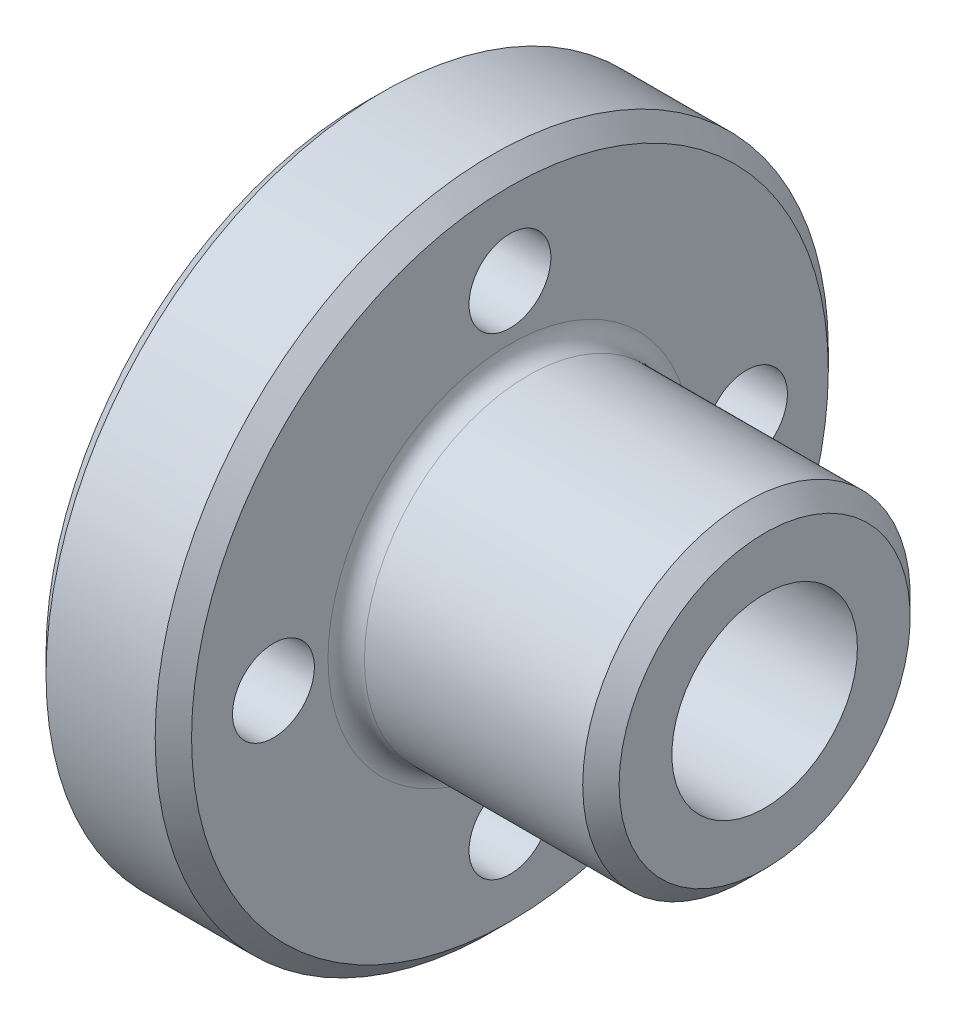
from build123d import *

# Parameters (mm, degrees)
FORO_LAMATO_PER_VITE_M4_A_TESTA_CILINDRI_D           = 4.5
FORO_LAMATO_PER_VITE_M4_A_TESTA_CILINDRI_CBORE_D     = 8
FORO_LAMATO_PER_VITE_M4_A_TESTA_CILINDRI_CBORE_DEPTH = 2.6
RIPETIZIONECIRCOLARE1_COUNT                          = 4
RACCORDO1_R                                          = 1
SMUSSO1_SIZE                                         = 1
FORO_FILETTATO_M12_1_D                               = 10.2
FORO_FILETTATO_M12_1_DEPTH                           = 32.75
FORO_FILETTATO_M12_1_TIP                             = 3.064389157
SMUSSO2_SIZE                                         = 1


with BuildPart() as part:
    # Schizzo1 → Rivoluzione1 (revolve)
    with BuildSketch(Plane.XY):
        Polygon((0, 0), (0, 18.5), (8, 18.5), (8, 9), (22, 9), (22, 0), align=None)
    revolve(axis=Axis((22, 0, 0), (-1, 0, 0)))

    # Foro lamato per Vite M4 a testa cilindrica piana-1 (through all)
    with Locations(Plane.ZY):
        with Locations((0, 13)):
            foro_lamato_per_vite_m4_a_testa_cilindri = CounterBoreHole(FORO_LAMATO_PER_VITE_M4_A_TESTA_CILINDRI_D / 2, FORO_LAMATO_PER_VITE_M4_A_TESTA_CILINDRI_CBORE_D / 2, FORO_LAMATO_PER_VITE_M4_A_TESTA_CILINDRI_CBORE_DEPTH)

    # RipetizioneCircolare1: Foro lamato per Vite M4 a testa cilindrica piana-1 ×4 about axis
    ripetizionecircolare1_axis = Axis((0, 0, 0), (1, 0, 0))
    for i in range(1, RIPETIZIONECIRCOLARE1_COUNT):
        add(foro_lamato_per_vite_m4_a_testa_cilindri.rotate(ripetizionecircolare1_axis, i * 360 / RIPETIZIONECIRCOLARE1_COUNT), mode=Mode.SUBTRACT)

    # Raccordo1
    raccordo1_edges = [part.edges().sort_by_distance(p)[0] for p in [
        (8, -9, 0),
    ]]
    fillet(raccordo1_edges, radius=RACCORDO1_R)

    # Smusso1
    smusso1_edges = [part.edges().sort_by_distance(p)[0] for p in [
        (22, -9, 0),
        (8, -18.5, 0),
        (0, -18.5, 0),
    ]]
    chamfer(smusso1_edges, length=SMUSSO1_SIZE)

    # Foro filettato M12-1
    with Locations(Plane(origin=(22, 0, 0), x_dir=(0, 0, -1), z_dir=(1, 0, 0))):
        with Locations((0, 0)):
            Hole(FORO_FILETTATO_M12_1_D / 2, depth=FORO_FILETTATO_M12_1_DEPTH)
            with Locations((0, 0, -(FORO_FILETTATO_M12_1_DEPTH + FORO_FILETTATO_M12_1_TIP / 2))):  # 118° drill point
                Cone(0, FORO_FILETTATO_M12_1_D / 2, FORO_FILETTATO_M12_1_TIP, mode=Mode.SUBTRACT)

    # Smusso2
    smusso2_edges = [part.edges().sort_by_distance(p)[0] for p in [
        (0, 0, -5.1),
    ]]
    chamfer(smusso2_edges, length=SMUSSO2_SIZE)


solid = part.part
